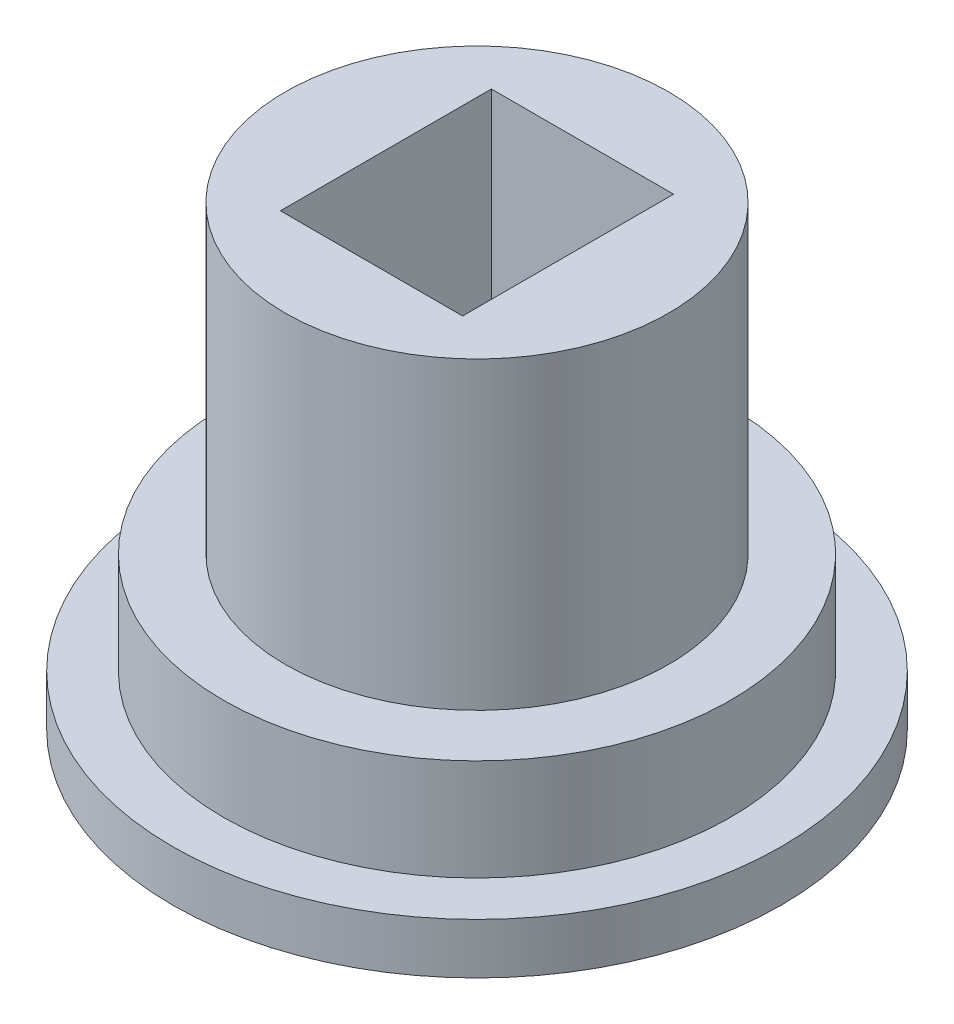
from build123d import *

# Parameters (mm, degrees)
SKETCH1_R           = 6.35
BOSS_EXTRUDE1_DEPTH = 2.54
SKETCH2_R           = 4.8006
BOSS_EXTRUDE2_DEPTH = 7.62
SKETCH3_W           = 4.562763636
SKETCH3_H           = 5.2832
CUT_EXTRUDE1_DEPTH  = 7.62
SKETCH6_R           = 7.62
BOSS_EXTRUDE3_DEPTH = 1.27
SKETCH4_R           = 0.762
CUT_EXTRUDE2_DEPTH  = 4.81
SKETCH5_R           = 0.762
CUT_EXTRUDE3_DEPTH  = 4.81


with BuildPart() as part:
    # Sketch1 → Boss-Extrude1 (new body)
    with BuildSketch(Plane(origin=(0, 0, 0), x_dir=(1, 0, 0), z_dir=(0, 1, 0))):
        Circle(SKETCH1_R)
    extrude(amount=BOSS_EXTRUDE1_DEPTH)

    # Sketch2 → Boss-Extrude2 (add)
    with BuildSketch(Plane(origin=(0, 2.54, 0), x_dir=(1, 0, 0), z_dir=(0, 1, 0))):
        Circle(SKETCH2_R)
    extrude(amount=BOSS_EXTRUDE2_DEPTH)

    # Sketch3 → Cut-Extrude1 (cut)
    with BuildSketch(Plane(origin=(0, 10.16, 0), x_dir=(1, 0, 0), z_dir=(0, 1, 0))):
        Rectangle(SKETCH3_W, SKETCH3_H)
    extrude(amount=-CUT_EXTRUDE1_DEPTH, mode=Mode.SUBTRACT)

    # Sketch6 → Boss-Extrude3 (add)
    with BuildSketch(Plane.XZ):
        Circle(SKETCH6_R)
    extrude(amount=BOSS_EXTRUDE3_DEPTH)

    # Sketch4 → Cut-Extrude2 (cut, through all)
    with BuildSketch(Plane(origin=(0, 2.54, 0), x_dir=(1, 0, 0), z_dir=(0, 1, 0))):
        with Locations((0, -1.27)):
            Circle(SKETCH4_R)
    extrude(amount=-CUT_EXTRUDE2_DEPTH, mode=Mode.SUBTRACT)

    # Sketch5 → Cut-Extrude3 (cut, through all)
    with BuildSketch(Plane(origin=(0, 2.54, 0), x_dir=(1, 0, 0), z_dir=(0, 1, 0))):
        with Locations((0, 1.27)):
            Circle(SKETCH5_R)
    extrude(amount=-CUT_EXTRUDE3_DEPTH, mode=Mode.SUBTRACT)


solid = part.part
